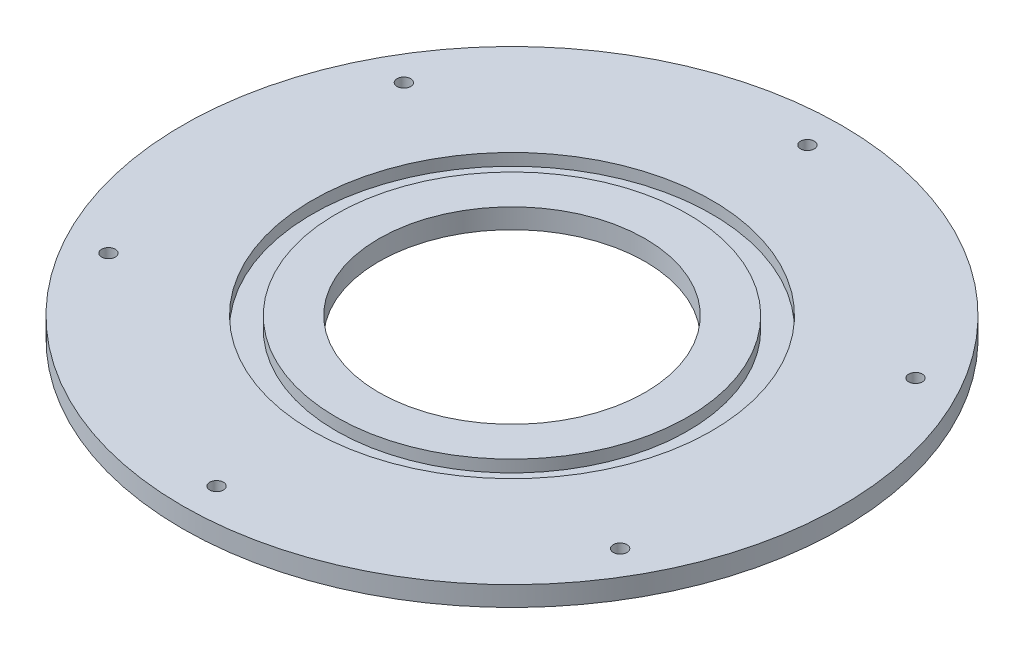
from build123d import *

# Parameters (mm, degrees)
SKETCH1_R           = 96.5
SKETCH1_R_2         = 39
BOSS_EXTRUDE1_DEPTH = 5.8
SKETCH2_R           = 58.5
SKETCH2_R_2         = 51.5
CUT_EXTRUDE1_DEPTH  = 3.5
SKETCH3_R           = 2
CUT_EXTRUDE2_DEPTH  = 6.8


with BuildPart() as part:
    # Sketch1 → Boss-Extrude1 (new body)
    with BuildSketch(Plane(origin=(0, 0, 0), x_dir=(1, 0, 0), z_dir=(0, 1, 0))):
        Circle(SKETCH1_R)
        Circle(SKETCH1_R_2, mode=Mode.SUBTRACT)
    extrude(amount=BOSS_EXTRUDE1_DEPTH)

    # Sketch2 → Cut-Extrude1 (cut)
    with BuildSketch(Plane(origin=(0, 5.8, 0), x_dir=(1, 0, 0), z_dir=(0, 1, 0))):
        Circle(SKETCH2_R)
        Circle(SKETCH2_R_2, mode=Mode.SUBTRACT)
    extrude(amount=-CUT_EXTRUDE1_DEPTH, mode=Mode.SUBTRACT)

    # Sketch3 → Cut-Extrude2 (cut, through all)
    with BuildSketch(Plane(origin=(0, 5.8, 0), x_dir=(1, 0, 0), z_dir=(0, 1, 0))):
        with Locations((0, 86.5)):
            Circle(SKETCH3_R)
        with Locations((74.911197427, 43.25)):
            Circle(SKETCH3_R)
        with Locations((74.911197427, -43.25)):
            Circle(SKETCH3_R)
        with Locations((0, -86.5)):
            Circle(SKETCH3_R)
        with Locations((-74.911197427, -43.25)):
            Circle(SKETCH3_R)
        with Locations((-74.911197427, 43.25)):
            Circle(SKETCH3_R)
    extrude(amount=-CUT_EXTRUDE2_DEPTH, mode=Mode.SUBTRACT)


solid = part.part
